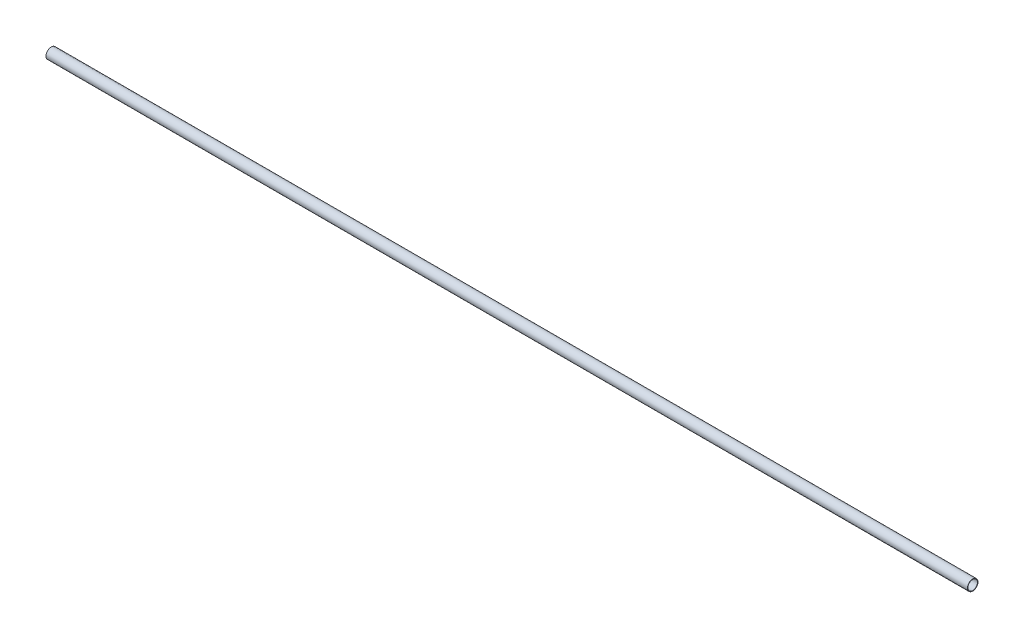
from build123d import *

# Parameters (mm, degrees)
SKETCH1_R           = 6.985
BOSS_EXTRUDE1_DEPTH = 1219.2
SKETCH2_R           = 6.35
CUT_EXTRUDE1_DEPTH  = 1220.2


with BuildPart() as part:
    # Sketch1 → Boss-Extrude1 (new body)
    with BuildSketch(Plane(origin=(0, 0, 0), x_dir=(0, 0, -1), z_dir=(1, 0, 0))):
        Circle(SKETCH1_R)
    extrude(amount=BOSS_EXTRUDE1_DEPTH)

    # Sketch2 → Cut-Extrude1 (cut, through all)
    with BuildSketch(Plane.ZY):
        Circle(SKETCH2_R)
    extrude(amount=-CUT_EXTRUDE1_DEPTH, mode=Mode.SUBTRACT)


solid = part.part
